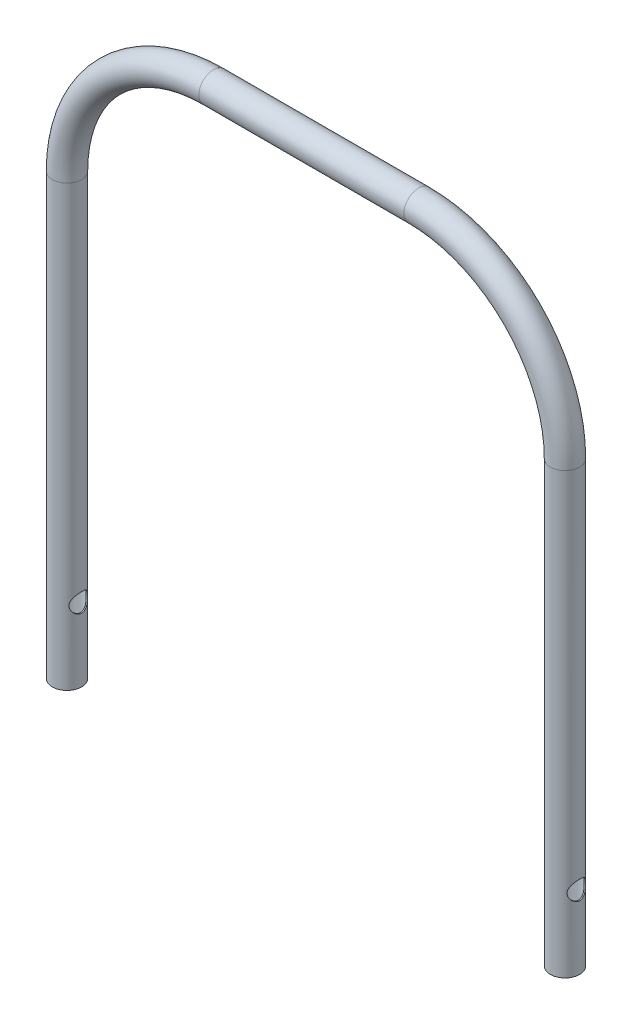
from build123d import *

# Parameters (mm, degrees)
SKETCH1_R                        = 10
SKETCH1_R_2                      = 9.25
ROUND_TUBE_DO20_DI18_5_1_DEPTH   = 300
SKETCH1_ON_SEGMENT_2_R           = 10
SKETCH1_ON_SEGMENT_2_R_2         = 9.25
ROUND_TUBE_DO20_DI18_5_1_2_ANGLE = 90
SKETCH1_ON_SEGMENT_3_R           = 10
SKETCH1_ON_SEGMENT_3_R_2         = 9.25
ROUND_TUBE_DO20_DI18_5_1_3_DEPTH = 140
SKETCH1_ON_SEGMENT_4_R           = 10
SKETCH1_ON_SEGMENT_4_R_2         = 9.25
ROUND_TUBE_DO20_DI18_5_1_4_ANGLE = 90
SKETCH1_ON_SEGMENT_5_R           = 10
SKETCH1_ON_SEGMENT_5_R_2         = 9.25
ROUND_TUBE_DO20_DI18_5_1_5_DEPTH = 300
SKETCH6_W                        = 6.35
SKETCH6_H                        = 410


with BuildPart() as part:
    # Sketch1 → Round_tube DO20_DI18_5(1) (new body)
    with BuildSketch(Plane(origin=(0, 0, 0), x_dir=(-1, 0, 0), z_dir=(0, 1, 0))):
        Circle(SKETCH1_R)
        Circle(SKETCH1_R_2, mode=Mode.SUBTRACT)
    extrude(amount=ROUND_TUBE_DO20_DI18_5_1_DEPTH)


with BuildPart() as body_2:
    # Sketch1 on segment 2 (carried to the start of arc 2) → Round_tube DO20_DI18_5_1 2 (revolve)
    with BuildSketch(Plane(origin=(0, 300, 0), x_dir=(-1, 0, 0), z_dir=(0, 1, 0))):
        Circle(SKETCH1_ON_SEGMENT_2_R)
        Circle(SKETCH1_ON_SEGMENT_2_R_2, mode=Mode.SUBTRACT)
    revolve(axis=Axis((-100, 300, 0), (0, 0, 1)), revolution_arc=ROUND_TUBE_DO20_DI18_5_1_2_ANGLE)


with BuildPart() as body_3:
    # Sketch1 on segment 3 (carried to segment 3) → Round_tube DO20_DI18_5_1 3 (new body)
    with BuildSketch(Plane(origin=(-100, 400, 0), x_dir=(0, -1, 0), z_dir=(-1, 0, 0))):
        Circle(SKETCH1_ON_SEGMENT_3_R)
        Circle(SKETCH1_ON_SEGMENT_3_R_2, mode=Mode.SUBTRACT)
    extrude(amount=ROUND_TUBE_DO20_DI18_5_1_3_DEPTH)


with BuildPart() as body_4:
    # Sketch1 on segment 4 (carried to the start of arc 4) → Round_tube DO20_DI18_5_1 4 (revolve)
    with BuildSketch(Plane(origin=(-340, 300, 0), x_dir=(-1, 0, 0), z_dir=(0, 1, 0))):
        Circle(SKETCH1_ON_SEGMENT_4_R)
        Circle(SKETCH1_ON_SEGMENT_4_R_2, mode=Mode.SUBTRACT)
    revolve(axis=Axis((-240, 300, 0), (0, 0, -1)), revolution_arc=ROUND_TUBE_DO20_DI18_5_1_4_ANGLE)


with BuildPart() as body_5:
    # Sketch1 on segment 5 (carried to segment 5) → Round_tube DO20_DI18_5_1 5 (new body)
    with BuildSketch(Plane(origin=(-340, 0, 0), x_dir=(-1, 0, 0), z_dir=(0, 1, 0))):
        Circle(SKETCH1_ON_SEGMENT_5_R)
        Circle(SKETCH1_ON_SEGMENT_5_R_2, mode=Mode.SUBTRACT)
    extrude(amount=ROUND_TUBE_DO20_DI18_5_1_5_DEPTH)


with BuildPart() as f_12_0mm_dowel_hole2_tool:
    # Sketch6 → Ø12.0mm Dowel Hole2 (revolve)
    with BuildSketch(Plane(origin=(-400, 50, 0), x_dir=(0, 0, 1), z_dir=(0, 1, 0))):
        with Locations((3.175, 205)):
            Rectangle(SKETCH6_W, SKETCH6_H)
    revolve(axis=Axis((-406.35, 50, 0), (1, 0, 0)))


with BuildPart() as part_1:
    add(part.part)

    # Ø12.0mm Dowel Hole2: cut by f_12_0mm_dowel_hole2_tool
    add(f_12_0mm_dowel_hole2_tool.part, mode=Mode.SUBTRACT)


with BuildPart() as body_5_1:
    add(body_5.part)

    # Ø12.0mm Dowel Hole2: cut by f_12_0mm_dowel_hole2_tool
    add(f_12_0mm_dowel_hole2_tool.part, mode=Mode.SUBTRACT)


solid = Compound([body_2.part, body_3.part, body_4.part, part_1.part, body_5_1.part])
